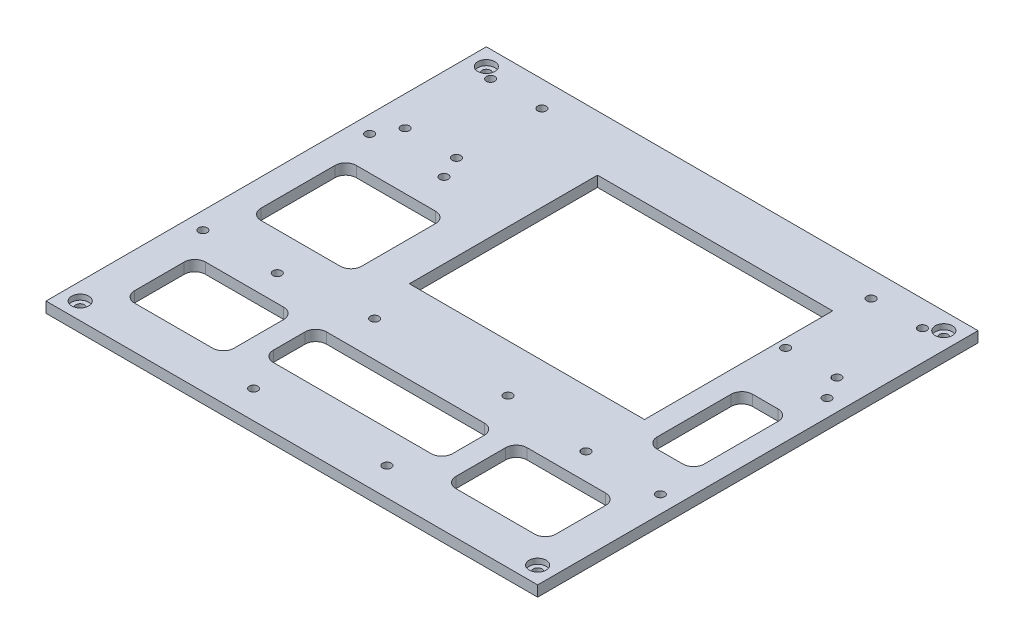
from build123d import *

# Parameters (mm, degrees)
SKETCH1_W           = 119
SKETCH1_H           = 103
BOSS_EXTRUDE1_DEPTH = 2.5
SKETCH3_W           = 55
SKETCH3_H           = 44
CUT_EXTRUDE2_DEPTH  = 10
SKETCH4_W           = 103
SKETCH4_H           = 2.5
BOSS_EXTRUDE2_DEPTH = 1.5
SKETCH5_W           = 103
SKETCH5_H           = 2.5
BOSS_EXTRUDE3_DEPTH = 1.5
SKETCH6_W           = 103
SKETCH6_H           = 2.5
CUT_EXTRUDE3_DEPTH  = 3.5
SKETCH7_W           = 103
SKETCH7_H           = 2.5
CUT_EXTRUDE4_DEPTH  = 3.5
SKETCH8_R           = 1
CUT_EXTRUDE5_DEPTH  = 10
SKETCH9_R           = 1
CUT_EXTRUDE6_DEPTH  = 10
SKETCH10_R          = 2
CUT_EXTRUDE7_DEPTH  = 1.25
SKETCH11_R          = 1
CUT_EXTRUDE8_DEPTH  = 11
CUT_EXTRUDE9_DEPTH  = 11


with BuildPart() as part:
    # Sketch1 → Boss-Extrude1 (new body)
    with BuildSketch(Plane(origin=(0, 0, 0), x_dir=(1, 0, 0), z_dir=(0, 1, 0))):
        Rectangle(SKETCH1_W, SKETCH1_H)
    extrude(amount=BOSS_EXTRUDE1_DEPTH)

    # Sketch3 → Cut-Extrude2 (cut)
    with BuildSketch(Plane(origin=(0, 2.5, 0), x_dir=(1, 0, 0), z_dir=(0, 1, 0))):
        with Locations((9, 16.5)):
            Rectangle(SKETCH3_W, SKETCH3_H)
    extrude(amount=-CUT_EXTRUDE2_DEPTH, mode=Mode.SUBTRACT)

    # Sketch4 → Boss-Extrude2 (add)
    with BuildSketch(Plane.ZY.offset(59.5)):
        with Locations((0, 1.25)):
            Rectangle(SKETCH4_W, SKETCH4_H)
    extrude(amount=BOSS_EXTRUDE2_DEPTH)

    # Sketch5 → Boss-Extrude3 (add)
    with BuildSketch(Plane(origin=(59.5, 0, 0), x_dir=(0, 0, -1), z_dir=(1, 0, 0))):
        with Locations((0, 1.25)):
            Rectangle(SKETCH5_W, SKETCH5_H)
    extrude(amount=BOSS_EXTRUDE3_DEPTH)

    # Sketch6 → Cut-Extrude3 (cut)
    with BuildSketch(Plane.ZY.offset(61)):
        with Locations((0, 1.25)):
            Rectangle(SKETCH6_W, SKETCH6_H)
    extrude(amount=-CUT_EXTRUDE3_DEPTH, mode=Mode.SUBTRACT)

    # Sketch7 → Cut-Extrude4 (cut)
    with BuildSketch(Plane(origin=(61, 0, 0), x_dir=(0, 0, -1), z_dir=(1, 0, 0))):
        with Locations((0, 1.25)):
            Rectangle(SKETCH7_W, SKETCH7_H)
    extrude(amount=-CUT_EXTRUDE4_DEPTH, mode=Mode.SUBTRACT)

    # Sketch8 → Cut-Extrude5 (cut)
    with BuildSketch(Plane(origin=(0, 2.5, 0), x_dir=(1, 0, 0), z_dir=(0, 1, 0))):
        with Locations((-15.5, -44.96)):
            Circle(SKETCH8_R)
        with Locations((15.7, -44.96)):
            Circle(SKETCH8_R)
        with Locations((-15.5, -16.63)):
            Circle(SKETCH8_R)
        with Locations((15.7, -16.63)):
            Circle(SKETCH8_R)
        with Locations((-53.5, -18.81)):
            Circle(SKETCH8_R)
        with Locations((-36.1, -18.81)):
            Circle(SKETCH8_R)
        with Locations((-53.5, 20.19)):
            Circle(SKETCH8_R)
        with Locations((-36.1, 20.19)):
            Circle(SKETCH8_R)
        with Locations((36.1, -18.81)):
            Circle(SKETCH8_R)
        with Locations((53.5, -18.81)):
            Circle(SKETCH8_R)
        with Locations((53.5, 20.19)):
            Circle(SKETCH8_R)
    extrude(amount=-CUT_EXTRUDE5_DEPTH, mode=Mode.SUBTRACT)

    # Sketch9 → Cut-Extrude6 (cut)
    with BuildSketch(Plane(origin=(0, 2.5, 0), x_dir=(1, 0, 0), z_dir=(0, 1, 0))):
        with Locations((-53.5, 47.5)):
            Circle(SKETCH9_R)
        with Locations((53.5, -47.5)):
            Circle(SKETCH9_R)
        with Locations((53.5, 47.5)):
            Circle(SKETCH9_R)
        with Locations((-53.5, -47.5)):
            Circle(SKETCH9_R)
    extrude(amount=-CUT_EXTRUDE6_DEPTH, mode=Mode.SUBTRACT)

    # Sketch10 → Cut-Extrude7 (cut)
    with BuildSketch(Plane(origin=(0, 2.5, 0), x_dir=(1, 0, 0), z_dir=(0, 1, 0))):
        with Locations((-53.5, 47.5)):
            Circle(SKETCH10_R)
        with Locations((-53.5, -47.5)):
            Circle(SKETCH10_R)
        with Locations((53.5, -47.5)):
            Circle(SKETCH10_R)
        with Locations((53.5, 47.5)):
            Circle(SKETCH10_R)
    extrude(amount=-CUT_EXTRUDE7_DEPTH, mode=Mode.SUBTRACT)

    # Sketch11 → Cut-Extrude8 (cut)
    with BuildSketch(Plane(origin=(0, 2.5, 0), x_dir=(1, 0, 0), z_dir=(0, 1, 0))):
        with Locations((-50.5, 45.5)):
            Circle(SKETCH11_R)
        with Locations((-50.5, 25.5)):
            Circle(SKETCH11_R)
        with Locations((-38.5, 45.5)):
            Circle(SKETCH11_R)
        with Locations((-38.5, 25.5)):
            Circle(SKETCH11_R)
        with Locations((50.5, 25.5)):
            Circle(SKETCH11_R)
        with Locations((38.5, 25.5)):
            Circle(SKETCH11_R)
        with Locations((38.5, 45.5)):
            Circle(SKETCH11_R)
        with Locations((50.5, 45.5)):
            Circle(SKETCH11_R)
    extrude(amount=-CUT_EXTRUDE8_DEPTH, mode=Mode.SUBTRACT)

    # Sketch12 → Cut-Extrude9 (cut)
    with BuildSketch(Plane(origin=(0, 2.5, 0), x_dir=(1, 0, 0), z_dir=(0, 1, 0))):
        with BuildLine():
            Line((-46.739053949, -24.945491093), (-28.457129996, -24.945491093))
            ThreePointArc((-28.457129996, -24.945491093), (-26.689363043, -25.67772414), (-25.957129996, -27.445491093))
            Line((-25.957129996, -27.445491093), (-25.957129996, -39.065269049))
            ThreePointArc((-25.957129996, -39.065269049), (-26.689363043, -40.833036002), (-28.457129996, -41.565269049))
            Line((-28.457129996, -41.565269049), (-46.739053949, -41.565269049))
            ThreePointArc((-46.739053949, -41.565269049), (-48.506820902, -40.833036002), (-49.239053949, -39.065269049))
            Line((-49.239053949, -39.065269049), (-49.239053949, -27.445491093))
            ThreePointArc((-49.239053949, -27.445491093), (-48.506820902, -25.67772414), (-46.739053949, -24.945491093))
        make_face()
        with BuildLine():
            Line((-48.675698452, -10.035902375), (-30.13630944, -10.035902375))
            ThreePointArc((-30.13630944, -10.035902375), (-28.368542487, -9.303669328), (-27.63630944, -7.535902375))
            Line((-27.63630944, -7.535902375), (-27.63630944, 9.759475357))
            ThreePointArc((-27.63630944, 9.759475357), (-28.368542487, 11.52724231), (-30.13630944, 12.259475357))
            Line((-30.13630944, 12.259475357), (-48.675698452, 12.259475357))
            ThreePointArc((-48.675698452, 12.259475357), (-50.443465405, 11.52724231), (-51.175698452, 9.759475357))
            Line((-51.175698452, 9.759475357), (-51.175698452, -7.535902375))
            ThreePointArc((-51.175698452, -7.535902375), (-50.443465405, -9.303669328), (-48.675698452, -10.035902375))
        make_face()
        with BuildLine():
            Line((-20.957129996, -27.445491093), (-20.957129996, -34.866758765))
            ThreePointArc((-20.957129996, -34.866758765), (-20.224896949, -36.634525718), (-18.457129996, -37.366758765))
            Line((-18.457129996, -37.366758765), (18.457129996, -37.366758765))
            ThreePointArc((18.457129996, -37.366758765), (20.224896949, -36.634525718), (20.957129996, -34.866758765))
            Line((20.957129996, -34.866758765), (20.957129996, -27.445491093))
            ThreePointArc((20.957129996, -27.445491093), (20.224896949, -25.67772414), (18.457129996, -24.945491093))
            Line((18.457129996, -24.945491093), (-18.457129996, -24.945491093))
            ThreePointArc((-18.457129996, -24.945491093), (-20.224896949, -25.67772414), (-20.957129996, -27.445491093))
        make_face()
        with BuildLine():
            Line((28.457129996, -41.565269049), (46.850265705, -41.565269049))
            ThreePointArc((46.850265705, -41.565269049), (48.618032658, -40.833036002), (49.350265705, -39.065269049))
            Line((49.350265705, -39.065269049), (49.350265705, -27.445491093))
            ThreePointArc((49.350265705, -27.445491093), (48.618032658, -25.67772414), (46.850265705, -24.945491093))
            Line((46.850265705, -24.945491093), (28.457129996, -24.945491093))
            ThreePointArc((28.457129996, -24.945491093), (26.689363043, -25.67772414), (25.957129996, -27.445491093))
            Line((25.957129996, -27.445491093), (25.957129996, -39.065269049))
            ThreePointArc((25.957129996, -39.065269049), (26.689363043, -40.833036002), (28.457129996, -41.565269049))
        make_face()
        with BuildLine():
            Line((41.5, 9.759475357), (41.5, -7.535902375))
            ThreePointArc((41.5, -7.535902375), (42.232233047, -9.303669328), (44, -10.035902375))
            Line((44, -10.035902375), (50, -10.035902375))
            ThreePointArc((50, -10.035902375), (51.767766953, -9.303669328), (52.5, -7.535902375))
            Line((52.5, -7.535902375), (52.5, 9.759475357))
            ThreePointArc((52.5, 9.759475357), (51.767766953, 11.52724231), (50, 12.259475357))
            Line((50, 12.259475357), (44, 12.259475357))
            ThreePointArc((44, 12.259475357), (42.232233047, 11.52724231), (41.5, 9.759475357))
        make_face()
    extrude(amount=-CUT_EXTRUDE9_DEPTH, mode=Mode.SUBTRACT)


solid = part.part
